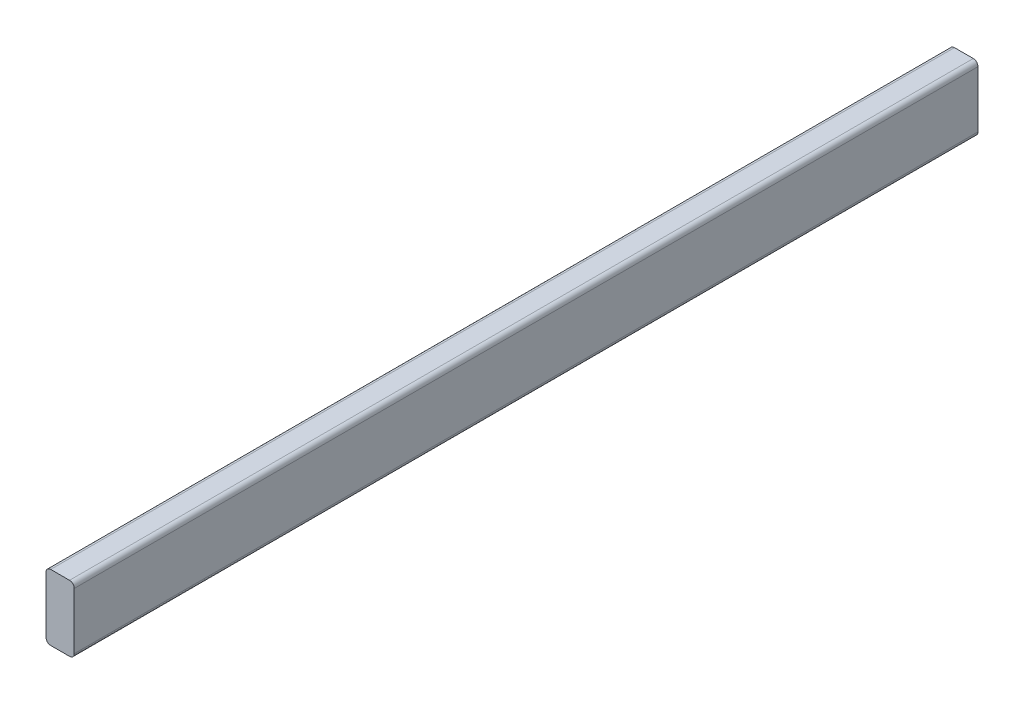
from build123d import *

# Parameters (mm, degrees)
BOSS_EXTRUDE1_DEPTH = 1219.2


with BuildPart() as part:
    # Sketch2 → Boss-Extrude1 (new body)
    with BuildSketch(Plane.XY):
        with BuildLine():
            Line((-12.7, 44.45), (12.7, 44.45))
            ThreePointArc((12.7, 44.45), (17.190128061, 42.590128061), (19.05, 38.1))
            Line((19.05, 38.1), (19.05, -38.1))
            ThreePointArc((19.05, -38.1), (17.190128061, -42.590128061), (12.7, -44.45))
            Line((12.7, -44.45), (-12.7, -44.45))
            ThreePointArc((-12.7, -44.45), (-17.190128061, -42.590128061), (-19.05, -38.1))
            Line((-19.05, -38.1), (-19.05, 38.1))
            ThreePointArc((-19.05, 38.1), (-17.190128061, 42.590128061), (-12.7, 44.45))
        make_face()
    extrude(amount=BOSS_EXTRUDE1_DEPTH)


solid = part.part
